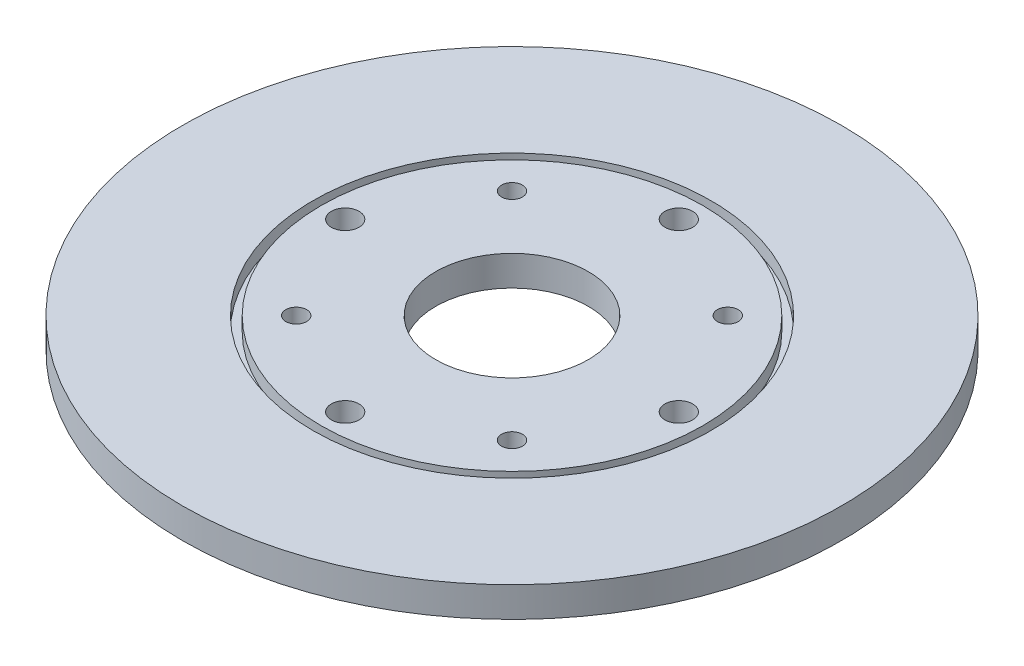
from build123d import *

# Parameters (mm, degrees)
SKETCH1_R           = 47.5
SKETCH1_R_2         = 11
SKETCH1_R_3         = 1.5
BOSS_EXTRUDE1_DEPTH = 4.34
SKETCH2_R           = 28.7
SKETCH2_R_2         = 27.5
CUT_EXTRUDE1_DEPTH  = 2
CUT_EXTRUDE2_REACH  = 6.34
SKETCH3_R           = 2


with BuildPart() as part:
    # Sketch1 → Boss-Extrude1 (new body)
    with BuildSketch(Plane(origin=(0, 0, 0), x_dir=(1, 0, 0), z_dir=(0, 1, 0))):
        Circle(SKETCH1_R)
        Circle(SKETCH1_R_2, mode=Mode.SUBTRACT)
        with Locations((15.55, 15.55)):
            Circle(SKETCH1_R_3, mode=Mode.SUBTRACT)
        with Locations((15.55, -15.55)):
            Circle(SKETCH1_R_3, mode=Mode.SUBTRACT)
        with Locations((-15.55, -15.55)):
            Circle(SKETCH1_R_3, mode=Mode.SUBTRACT)
        with Locations((-15.55, 15.55)):
            Circle(SKETCH1_R_3, mode=Mode.SUBTRACT)
    extrude(amount=BOSS_EXTRUDE1_DEPTH)

    # Sketch2 → Cut-Extrude1 (cut)
    with BuildSketch(Plane(origin=(0, 4.34, 0), x_dir=(1, 0, 0), z_dir=(0, 1, 0))):
        Circle(SKETCH2_R)
        Circle(SKETCH2_R_2, mode=Mode.SUBTRACT)
    extrude(amount=-CUT_EXTRUDE1_DEPTH, mode=Mode.SUBTRACT)

    # Sketch3 → Cut-Extrude2 (cut, up to next)
    with BuildSketch(Plane(origin=(0, 4.34, 0), x_dir=(1, 0, 0), z_dir=(0, 1, 0)), mode=Mode.PRIVATE) as cut_extrude2_sk1:
        with Locations((24.04163056, 0)):
            Circle(SKETCH3_R)
    cut_extrude2_tool1 = extrude(cut_extrude2_sk1.sketch, amount=-CUT_EXTRUDE2_REACH, mode=Mode.PRIVATE) & part.part
    add(cut_extrude2_tool1.solids().sort_by_distance((24.041631, 4.34, 0))[0], mode=Mode.SUBTRACT)
    # Sketch3 → Cut-Extrude2 (cut, up to next)
    with BuildSketch(Plane(origin=(0, 4.34, 0), x_dir=(1, 0, 0), z_dir=(0, 1, 0)), mode=Mode.PRIVATE) as cut_extrude2_sk2:
        with Locations((0, -24.04163056)):
            Circle(SKETCH3_R)
    cut_extrude2_tool2 = extrude(cut_extrude2_sk2.sketch, amount=-CUT_EXTRUDE2_REACH, mode=Mode.PRIVATE) & part.part
    add(cut_extrude2_tool2.solids().sort_by_distance((0, 4.34, 24.041631))[0], mode=Mode.SUBTRACT)
    # Sketch3 → Cut-Extrude2 (cut, up to next)
    with BuildSketch(Plane(origin=(0, 4.34, 0), x_dir=(1, 0, 0), z_dir=(0, 1, 0)), mode=Mode.PRIVATE) as cut_extrude2_sk3:
        with Locations((-24.04163056, 0)):
            Circle(SKETCH3_R)
    cut_extrude2_tool3 = extrude(cut_extrude2_sk3.sketch, amount=-CUT_EXTRUDE2_REACH, mode=Mode.PRIVATE) & part.part
    add(cut_extrude2_tool3.solids().sort_by_distance((-24.041631, 4.34, 0))[0], mode=Mode.SUBTRACT)
    # Sketch3 → Cut-Extrude2 (cut, up to next)
    with BuildSketch(Plane(origin=(0, 4.34, 0), x_dir=(1, 0, 0), z_dir=(0, 1, 0)), mode=Mode.PRIVATE) as cut_extrude2_sk4:
        with Locations((0, 24.04163056)):
            Circle(SKETCH3_R)
    cut_extrude2_tool4 = extrude(cut_extrude2_sk4.sketch, amount=-CUT_EXTRUDE2_REACH, mode=Mode.PRIVATE) & part.part
    add(cut_extrude2_tool4.solids().sort_by_distance((0, 4.34, -24.041631))[0], mode=Mode.SUBTRACT)


solid = part.part
